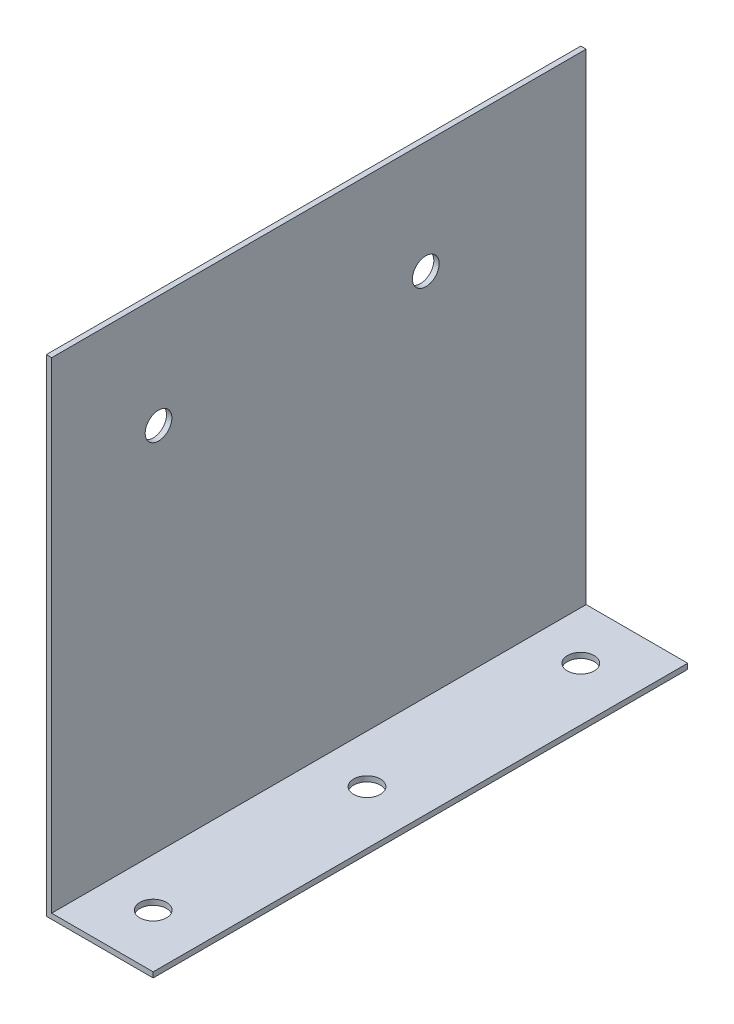
from build123d import *

# Parameters (mm, degrees)
SCHIZZO1_W                   = 20
SCHIZZO1_H                   = 100
ESTRUSIONE_ESTRUSIONE1_DEPTH = 1
SCHIZZO2_W                   = 1
SCHIZZO2_H                   = 100
ESTRUSIONE_ESTRUSIONE2_DEPTH = 90
SCHIZZO3_R                   = 2.5
TAGLIO_ESTRUSIONE1_DEPTH     = 42
SCHIZZO4_R                   = 2.5
TAGLIO_ESTRUSIONE2_DEPTH     = 42


with BuildPart() as part:
    # Schizzo1 → Estrusione-Estrusione1 (new body)
    with BuildSketch(Plane(origin=(0, 0, 0), x_dir=(1, 0, 0), z_dir=(0, 1, 0))):
        with Locations((10, -50)):
            Rectangle(SCHIZZO1_W, SCHIZZO1_H)
    extrude(amount=ESTRUSIONE_ESTRUSIONE1_DEPTH)

    # Schizzo2 → Estrusione-Estrusione2 (add)
    with BuildSketch(Plane(origin=(0, 1, 0), x_dir=(1, 0, 0), z_dir=(0, 1, 0))):
        with Locations((0.5, -50)):
            Rectangle(SCHIZZO2_W, SCHIZZO2_H)
    extrude(amount=ESTRUSIONE_ESTRUSIONE2_DEPTH)

    # Schizzo3 → Taglio-Estrusione1 (cut)
    with BuildSketch(Plane(origin=(0, 1, 0), x_dir=(1, 0, 0), z_dir=(0, 1, 0))):
        with Locations((10, -90)):
            Circle(SCHIZZO3_R)
        with Locations((10, -50)):
            Circle(SCHIZZO3_R)
        with Locations((10, -10)):
            Circle(SCHIZZO3_R)
    extrude(amount=-TAGLIO_ESTRUSIONE1_DEPTH, mode=Mode.SUBTRACT)

    # Schizzo4 → Taglio-Estrusione2 (cut)
    with BuildSketch(Plane(origin=(1, 0, 0), x_dir=(0, 0, -1), z_dir=(1, 0, 0))):
        with Locations((-30, 70)):
            Circle(SCHIZZO4_R)
        with Locations((-80, 70)):
            Circle(SCHIZZO4_R)
    extrude(amount=-TAGLIO_ESTRUSIONE2_DEPTH, mode=Mode.SUBTRACT)


solid = part.part
